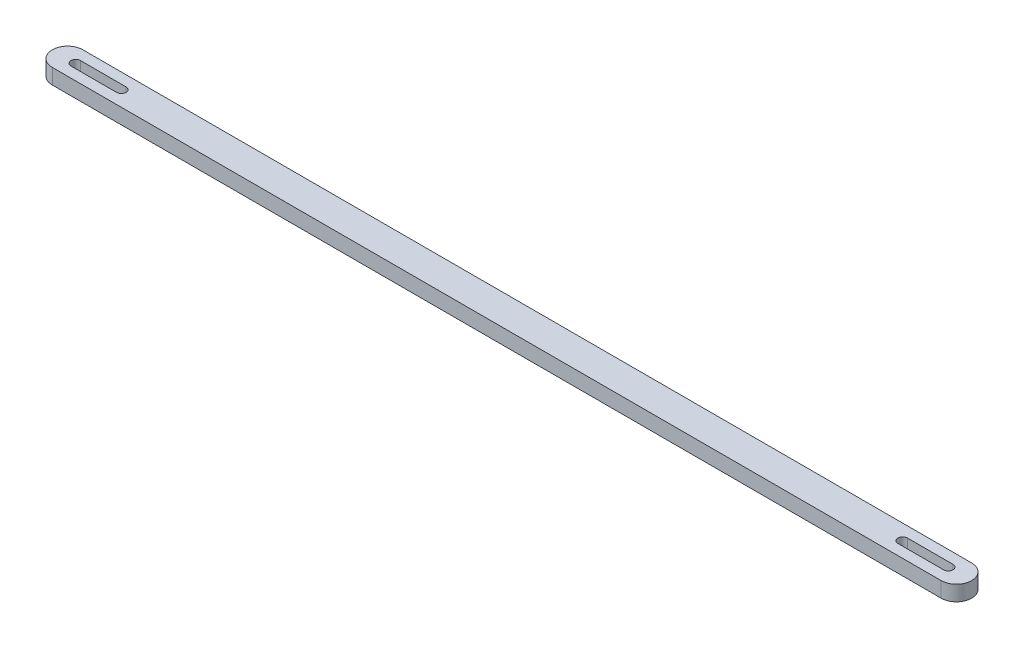
from build123d import *

# Parameters (mm, degrees)
EXTRUDE_1_DEPTH = 5


with BuildPart() as part:
    # 草圖1 → 填料-伸長1 (new body)
    with BuildSketch(Plane(origin=(0, 0, 0), x_dir=(1, 0, 0), z_dir=(0, 1, 0))):
        with BuildLine():
            Line((-145.5, 5), (145.5, 5))
            ThreePointArc((145.5, 5), (150.5, 0), (145.5, -5))
            Line((145.5, -5), (-145.5, -5))
            ThreePointArc((-145.5, -5), (-150.5, 0), (-145.5, 5))
        make_face()
        with BuildLine():
            Line((-127.890062181, -1.55), (-142.830345758, -1.55))
            ThreePointArc((-142.830345758, -1.55), (-144.380345758, 0), (-142.830345758, 1.55))
            Line((-142.830345758, 1.55), (-127.890062181, 1.55))
            ThreePointArc((-127.890062181, 1.55), (-126.340062181, 0), (-127.890062181, -1.55))
        make_face(mode=Mode.SUBTRACT)
        with BuildLine():
            Line((127.890062181, -1.55), (142.830345758, -1.55))
            ThreePointArc((142.830345758, -1.55), (144.380345758, 0), (142.830345758, 1.55))
            Line((142.830345758, 1.55), (127.890062181, 1.55))
            ThreePointArc((127.890062181, 1.55), (126.340062181, 0), (127.890062181, -1.55))
        make_face(mode=Mode.SUBTRACT)
    extrude(amount=EXTRUDE_1_DEPTH)


solid = part.part
